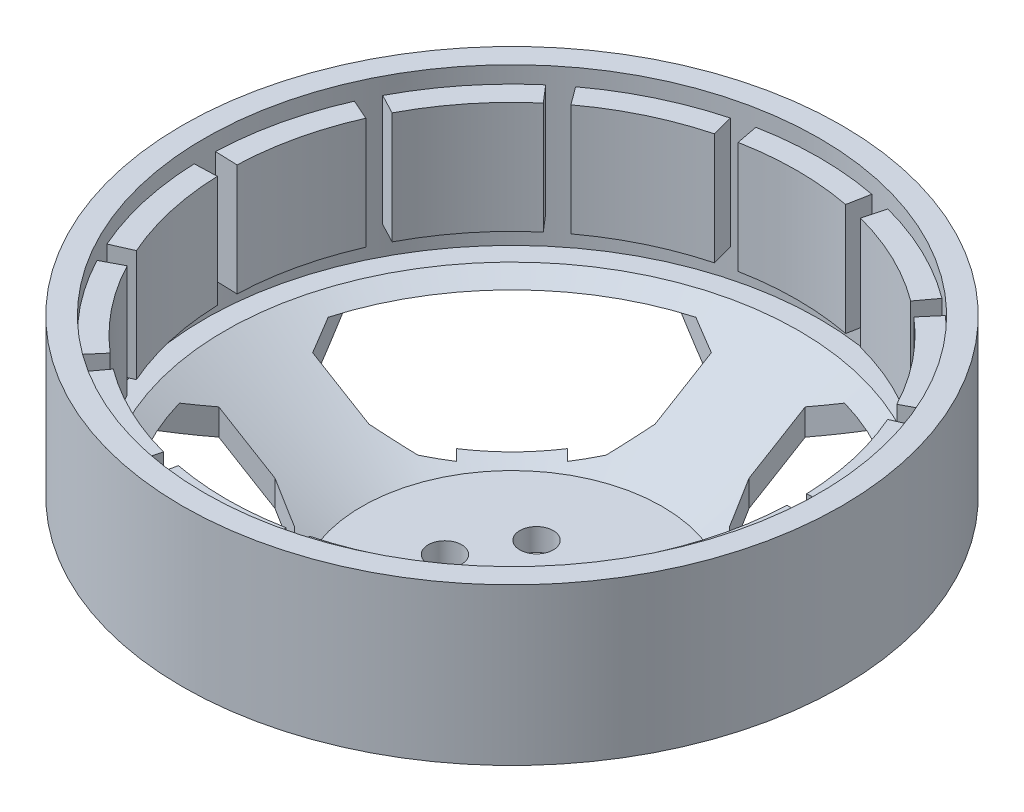
from build123d import *

# Parameters (mm, degrees)
IZIM1_R                           = 29.5
IZIM1_R_2                         = 27.5
Y_KSEKLIK_EKSTR_ZYON1_DEPTH       = 12
Y_KSEKLIK_EKSTR_ZYON3_START       = 0.5
Y_KSEKLIK_EKSTR_ZYON3_DEPTH       = 10
IZIM3_R                           = 29.5
IZIM3_R_2                         = 27.5
Y_KSEKLIK_EKSTR_ZYON4_DEPTH       = 2
CUT_EXTRUDE2_DEPTH                = 8.5
CIRPATTERN1_COUNT                 = 4
KES_EKSTR_ZYON2_REACH             = 25.5
IZIM10_R                          = 2
IZIM10_R_2                        = 1.5
KES_EKSTR_ZYON2_DIRECTION_2_DEPTH = 1


with BuildPart() as part:
    # Çizim1 → Yükseklik-Ekstrüzyon1 (new body)
    with BuildSketch(Plane(origin=(0, 0, 0), x_dir=(1, 0, 0), z_dir=(0, 1, 0))):
        Circle(IZIM1_R)
        Circle(IZIM1_R_2, mode=Mode.SUBTRACT)
    extrude(amount=Y_KSEKLIK_EKSTR_ZYON1_DEPTH)

    # Çizim2 → Yükseklik-Ekstrüzyon3 (add)
    with BuildSketch(Plane(origin=(0, 0, 0), x_dir=(1, 0, 0), z_dir=(0, 1, 0)).offset(Y_KSEKLIK_EKSTR_ZYON3_START)):
        with BuildLine():
            Line((4.811320755, 25.041988591), (5.188679245, 27.006066128))
            ThreePointArc((5.188679245, 27.006066128), (0, 27.5), (-5.188679245, 27.006066128))
            Line((-5.188679245, 27.006066128), (-4.811320755, 25.041988591))
            ThreePointArc((-4.811320755, 25.041988591), (0, 25.5), (4.811320755, 25.041988591))
        make_face()
        with BuildLine():
            Line((-6.530461431, 24.64960595), (-7.042654485, 26.582908378))
            ThreePointArc((-7.042654485, 26.582908378), (-11.931802826, 24.776643867), (-16.392331416, 22.080341273))
            Line((-16.392331416, 22.080341273), (-15.200161858, 20.474498272))
            ThreePointArc((-15.200161858, 20.474498272), (-11.064035347, 22.974706132), (-6.530461431, 24.64960595))
        make_face()
        with BuildLine():
            Line((-16.57880564, 19.375066543), (-17.879104122, 20.894679605))
            ThreePointArc((-17.879104122, 20.894679605), (-21.500365768, 17.145969551), (-24.349281311, 12.781334033))
            Line((-24.349281311, 12.781334033), (-22.578424488, 11.851782467))
            ThreePointArc((-22.578424488, 11.851782467), (-19.936702803, 15.898989947), (-16.57880564, 19.375066543))
        make_face()
        with BuildLine():
            Line((-23.343514066, 10.263057588), (-25.174377914, 11.068003281))
            ThreePointArc((-25.174377914, 11.068003281), (-26.810517585, 6.119325684), (-27.483557418, 0.950826834))
            Line((-27.483557418, 0.950826834), (-25.484753242, 0.881675791))
            ThreePointArc((-25.484753242, 0.881675791), (-24.860661761, 5.674283816), (-23.343514066, 10.263057588))
        make_face()
        with BuildLine():
            Line((-25.484753242, -0.881675791), (-27.483557418, -0.950826834))
            ThreePointArc((-27.483557418, -0.950826834), (-26.810517585, -6.119325684), (-25.174377914, -11.068003281))
            Line((-25.174377914, -11.068003281), (-23.343514066, -10.263057588))
            ThreePointArc((-23.343514066, -10.263057588), (-24.860661761, -5.674283816), (-25.484753242, -0.881675791))
        make_face()
        with BuildLine():
            Line((-22.578424488, -11.851782467), (-24.349281311, -12.781334033))
            ThreePointArc((-24.349281311, -12.781334033), (-21.500365768, -17.145969551), (-17.879104122, -20.894679605))
            Line((-17.879104122, -20.894679605), (-16.57880564, -19.375066543))
            ThreePointArc((-16.57880564, -19.375066543), (-19.936702803, -15.898989947), (-22.578424488, -11.851782467))
        make_face()
        with BuildLine():
            Line((-15.200161858, -20.474498272), (-16.392331416, -22.080341273))
            ThreePointArc((-16.392331416, -22.080341273), (-11.931802826, -24.776643867), (-7.042654485, -26.582908378))
            Line((-7.042654485, -26.582908378), (-6.530461431, -24.64960595))
            ThreePointArc((-6.530461431, -24.64960595), (-11.064035347, -22.974706132), (-15.200161858, -20.474498272))
        make_face()
        with BuildLine():
            Line((-4.811320755, -25.041988591), (-5.188679245, -27.006066128))
            ThreePointArc((-5.188679245, -27.006066128), (0, -27.5), (5.188679245, -27.006066128))
            Line((5.188679245, -27.006066128), (4.811320755, -25.041988591))
            ThreePointArc((4.811320755, -25.041988591), (0, -25.5), (-4.811320755, -25.041988591))
        make_face()
        with BuildLine():
            Line((6.530461431, -24.64960595), (7.042654485, -26.582908378))
            ThreePointArc((7.042654485, -26.582908378), (11.931802826, -24.776643867), (16.392331416, -22.080341273))
            Line((16.392331416, -22.080341273), (15.200161858, -20.474498272))
            ThreePointArc((15.200161858, -20.474498272), (11.064035347, -22.974706132), (6.530461431, -24.64960595))
        make_face()
        with BuildLine():
            Line((16.57880564, -19.375066543), (17.879104122, -20.894679605))
            ThreePointArc((17.879104122, -20.894679605), (21.500365768, -17.145969551), (24.349281311, -12.781334033))
            Line((24.349281311, -12.781334033), (22.578424488, -11.851782467))
            ThreePointArc((22.578424488, -11.851782467), (19.936702803, -15.898989947), (16.57880564, -19.375066543))
        make_face()
        with BuildLine():
            Line((23.343514066, -10.263057588), (25.174377914, -11.068003281))
            ThreePointArc((25.174377914, -11.068003281), (26.810517585, -6.119325684), (27.483557418, -0.950826834))
            Line((27.483557418, -0.950826834), (25.484753242, -0.881675791))
            ThreePointArc((25.484753242, -0.881675791), (24.860661761, -5.674283816), (23.343514066, -10.263057588))
        make_face()
        with BuildLine():
            Line((25.484753242, 0.881675791), (27.483557418, 0.950826834))
            ThreePointArc((27.483557418, 0.950826834), (26.810517585, 6.119325684), (25.174377914, 11.068003281))
            Line((25.174377914, 11.068003281), (23.343514066, 10.263057588))
            ThreePointArc((23.343514066, 10.263057588), (24.860661761, 5.674283816), (25.484753242, 0.881675791))
        make_face()
        with BuildLine():
            Line((22.578424488, 11.851782467), (24.349281311, 12.781334033))
            ThreePointArc((24.349281311, 12.781334033), (21.500365768, 17.145969551), (17.879104122, 20.894679605))
            Line((17.879104122, 20.894679605), (16.57880564, 19.375066543))
            ThreePointArc((16.57880564, 19.375066543), (19.936702803, 15.898989947), (22.578424488, 11.851782467))
        make_face()
        with BuildLine():
            Line((15.200161858, 20.474498272), (16.392331416, 22.080341273))
            ThreePointArc((16.392331416, 22.080341273), (11.931802826, 24.776643867), (7.042654485, 26.582908378))
            Line((7.042654485, 26.582908378), (6.530461431, 24.64960595))
            ThreePointArc((6.530461431, 24.64960595), (11.064035347, 22.974706132), (15.200161858, 20.474498272))
        make_face()
    extrude(amount=Y_KSEKLIK_EKSTR_ZYON3_DEPTH)

    # Çizim3 → Yükseklik-Ekstrüzyon4 (add)
    with BuildSketch(Plane.XZ):
        Circle(IZIM3_R)
        Circle(IZIM3_R_2, mode=Mode.SUBTRACT)
    extrude(amount=Y_KSEKLIK_EKSTR_ZYON4_DEPTH)

    # Çizim6 → Döndür1 (revolve)
    with BuildSketch(Plane(origin=(0, 0, 0), x_dir=(-1, 0, 0), z_dir=(0, 0, -1))):
        Polygon((-25.672703376, -2), (-29.5, -2), (-14, -11.5), (0, -11.5), (0, -9.5), (-13.435861271, -9.5), align=None)
    revolve(axis=Axis((0, -2, 0), (0, -1, 0)))

    # Sketch2 → Cut-Extrude2 (cut)
    with BuildSketch(Plane.XZ.offset(11.5)):
        with BuildLine():
            Line((0, 24.75), (10, 27.753378173))
            ThreePointArc((10, 27.753378173), (5.075694233, 29.060064144), (0, 29.5))
            Line((0, 29.5), (0, 24.75))
        make_face()
        with BuildLine():
            Line((4.2, 22.037068007), (4.2, 17))
            Line((4.2, 17), (5.52646368, 13.944826969))
            Line((5.52646368, 13.944826969), (7.26077159, 12.210519059))
            Line((7.26077159, 12.210519059), (7.798045982, 12.74779345))
            Line((7.798045982, 12.74779345), (12.74779345, 7.798045982))
            Line((12.74779345, 7.798045982), (12.210519059, 7.26077159))
            Line((12.210519059, 7.26077159), (13.944826969, 5.52646368))
            Line((13.944826969, 5.52646368), (17, 4.2))
            Line((17, 4.2), (22.037068007, 4.2))
            Line((22.037068007, 4.2), (26.145435584, 13.662583874))
            ThreePointArc((26.145435584, 13.662583874), (20.859650045, 20.859650045), (13.662583874, 26.145435584))
            Line((13.662583874, 26.145435584), (4.2, 22.037068007))
        make_face()
        with BuildLine():
            Line((24.75, 0), (29.5, 0))
            ThreePointArc((29.5, 0), (29.060064144, 5.075694233), (27.753378173, 10))
            Line((27.753378173, 10), (24.75, 0))
        make_face()
    cut_extrude2 = extrude(amount=-CUT_EXTRUDE2_DEPTH, mode=Mode.SUBTRACT)

    # CirPattern1: Cut-Extrude2 ×4 about axis
    cirpattern1_axis = Axis((0, 0, 0), (0, 1, 0))
    for i in range(1, CIRPATTERN1_COUNT):
        add(cut_extrude2.rotate(cirpattern1_axis, i * 360 / CIRPATTERN1_COUNT), mode=Mode.SUBTRACT)

    # Çizim10 → Kes-Ekstrüzyon2 (cut, up to next)
    with BuildSketch(Plane.XZ.offset(11.5), mode=Mode.PRIVATE) as kes_ekstr_zyon2_sk1:
        Circle(IZIM10_R)
    kes_ekstr_zyon2_tool1 = extrude(kes_ekstr_zyon2_sk1.sketch, amount=-KES_EKSTR_ZYON2_REACH, mode=Mode.PRIVATE) & part.part
    add(kes_ekstr_zyon2_tool1.solids().sort_by_distance((0, -11.5, 0))[0], mode=Mode.SUBTRACT)
    # Çizim10 → Kes-Ekstrüzyon2 (cut, up to next)
    with BuildSketch(Plane.XZ.offset(11.5), mode=Mode.PRIVATE) as kes_ekstr_zyon2_sk2:
        with Locations((6, 0)):
            Circle(IZIM10_R_2)
    kes_ekstr_zyon2_tool2 = extrude(kes_ekstr_zyon2_sk2.sketch, amount=-KES_EKSTR_ZYON2_REACH, mode=Mode.PRIVATE) & part.part
    add(kes_ekstr_zyon2_tool2.solids().sort_by_distance((6, -11.5, 0))[0], mode=Mode.SUBTRACT)
    # Çizim10 → Kes-Ekstrüzyon2 (cut, up to next)
    with BuildSketch(Plane.XZ.offset(11.5), mode=Mode.PRIVATE) as kes_ekstr_zyon2_sk3:
        with Locations((-6, 0)):
            Circle(IZIM10_R_2)
    kes_ekstr_zyon2_tool3 = extrude(kes_ekstr_zyon2_sk3.sketch, amount=-KES_EKSTR_ZYON2_REACH, mode=Mode.PRIVATE) & part.part
    add(kes_ekstr_zyon2_tool3.solids().sort_by_distance((-6, -11.5, 0))[0], mode=Mode.SUBTRACT)
    # Çizim10 → Kes-Ekstrüzyon2 (cut, up to next)
    with BuildSketch(Plane.XZ.offset(11.5), mode=Mode.PRIVATE) as kes_ekstr_zyon2_sk4:
        with Locations((-3, 5.196152423)):
            Circle(IZIM10_R_2)
    kes_ekstr_zyon2_tool4 = extrude(kes_ekstr_zyon2_sk4.sketch, amount=-KES_EKSTR_ZYON2_REACH, mode=Mode.PRIVATE) & part.part
    add(kes_ekstr_zyon2_tool4.solids().sort_by_distance((-3, -11.5, 5.196152))[0], mode=Mode.SUBTRACT)
    # Çizim10 → Kes-Ekstrüzyon2 (cut, up to next)
    with BuildSketch(Plane.XZ.offset(11.5), mode=Mode.PRIVATE) as kes_ekstr_zyon2_sk5:
        with Locations((3, 5.196152423)):
            Circle(IZIM10_R_2)
    kes_ekstr_zyon2_tool5 = extrude(kes_ekstr_zyon2_sk5.sketch, amount=-KES_EKSTR_ZYON2_REACH, mode=Mode.PRIVATE) & part.part
    add(kes_ekstr_zyon2_tool5.solids().sort_by_distance((3, -11.5, 5.196152))[0], mode=Mode.SUBTRACT)
    # Çizim10 → Kes-Ekstrüzyon2 (cut, up to next)
    with BuildSketch(Plane.XZ.offset(11.5), mode=Mode.PRIVATE) as kes_ekstr_zyon2_sk6:
        with Locations((3, -5.196152423)):
            Circle(IZIM10_R_2)
    kes_ekstr_zyon2_tool6 = extrude(kes_ekstr_zyon2_sk6.sketch, amount=-KES_EKSTR_ZYON2_REACH, mode=Mode.PRIVATE) & part.part
    add(kes_ekstr_zyon2_tool6.solids().sort_by_distance((3, -11.5, -5.196152))[0], mode=Mode.SUBTRACT)
    # Çizim10 → Kes-Ekstrüzyon2 (cut, up to next)
    with BuildSketch(Plane.XZ.offset(11.5), mode=Mode.PRIVATE) as kes_ekstr_zyon2_sk7:
        with Locations((-3, -5.196152423)):
            Circle(IZIM10_R_2)
    kes_ekstr_zyon2_tool7 = extrude(kes_ekstr_zyon2_sk7.sketch, amount=-KES_EKSTR_ZYON2_REACH, mode=Mode.PRIVATE) & part.part
    add(kes_ekstr_zyon2_tool7.solids().sort_by_distance((-3, -11.5, -5.196152))[0], mode=Mode.SUBTRACT)

    # Çizim10 → Kes-Ekstrüzyon2 direction 2 (cut)
    with BuildSketch(Plane.XZ.offset(11.5)):
        Circle(IZIM10_R)
        with Locations((6, 0)):
            Circle(IZIM10_R_2)
        with Locations((-6, 0)):
            Circle(IZIM10_R_2)
        with Locations((-3, 5.196152423)):
            Circle(IZIM10_R_2)
        with Locations((3, 5.196152423)):
            Circle(IZIM10_R_2)
        with Locations((3, -5.196152423)):
            Circle(IZIM10_R_2)
        with Locations((-3, -5.196152423)):
            Circle(IZIM10_R_2)
    extrude(amount=KES_EKSTR_ZYON2_DIRECTION_2_DEPTH, mode=Mode.SUBTRACT)


solid = part.part
